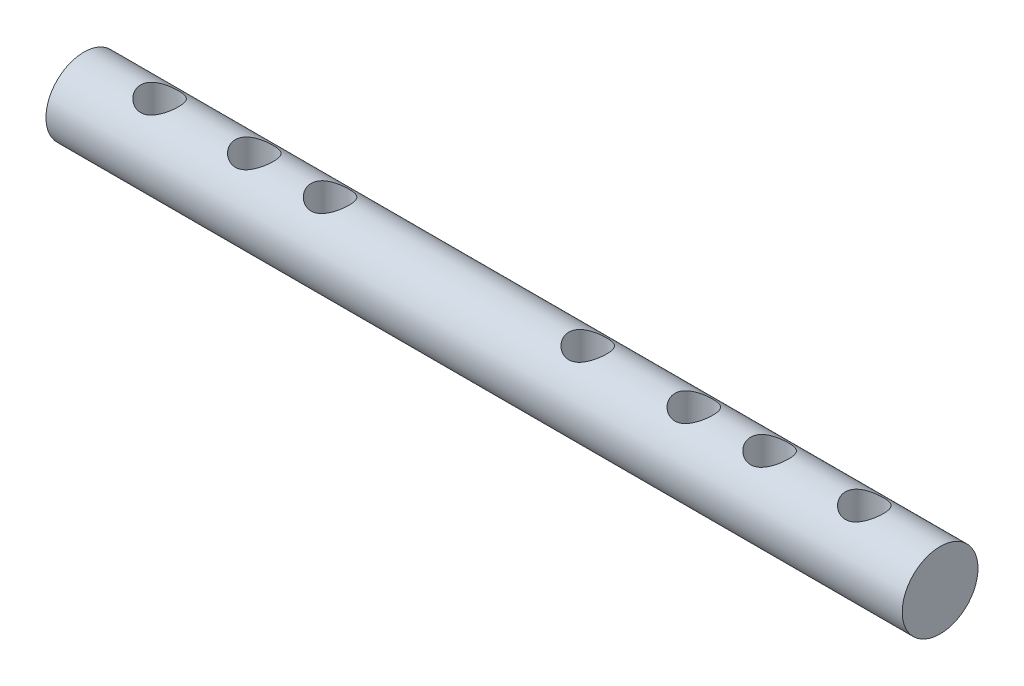
from build123d import *

# Parameters (mm, degrees)
SKETCH1_R               = 10
BOSS_EXTRUDE1_DEPTH     = 226
SKETCH2_R               = 5
CUT_EXTRUDE1_DEPTH      = 11
CUT_EXTRUDE1_DEPTH_BACK = 11


with BuildPart() as part:
    # Sketch1 → Boss-Extrude1 (new body)
    with BuildSketch(Plane(origin=(0, 0, 0), x_dir=(0, 0, -1), z_dir=(1, 0, 0))):
        Circle(SKETCH1_R)
    extrude(amount=BOSS_EXTRUDE1_DEPTH)

    # Sketch2 → Cut-Extrude1 (cut, two sides)
    with BuildSketch(Plane(origin=(0, 0, 0), x_dir=(1, 0, 0), z_dir=(0, 1, 0))) as cut_extrude1_sk:
        with Locations((20, 0)):
            Circle(SKETCH2_R)
        with Locations((206, 0)):
            Circle(SKETCH2_R)
        with Locations((181, 0)):
            Circle(SKETCH2_R)
        with Locations((45, 0)):
            Circle(SKETCH2_R)
        with Locations((161, 0)):
            Circle(SKETCH2_R)
        with Locations((65, 0)):
            Circle(SKETCH2_R)
        with Locations((133, 0)):
            Circle(SKETCH2_R)
    extrude(amount=CUT_EXTRUDE1_DEPTH, mode=Mode.SUBTRACT)
    extrude(cut_extrude1_sk.sketch, amount=-CUT_EXTRUDE1_DEPTH_BACK, mode=Mode.SUBTRACT)


solid = part.part
